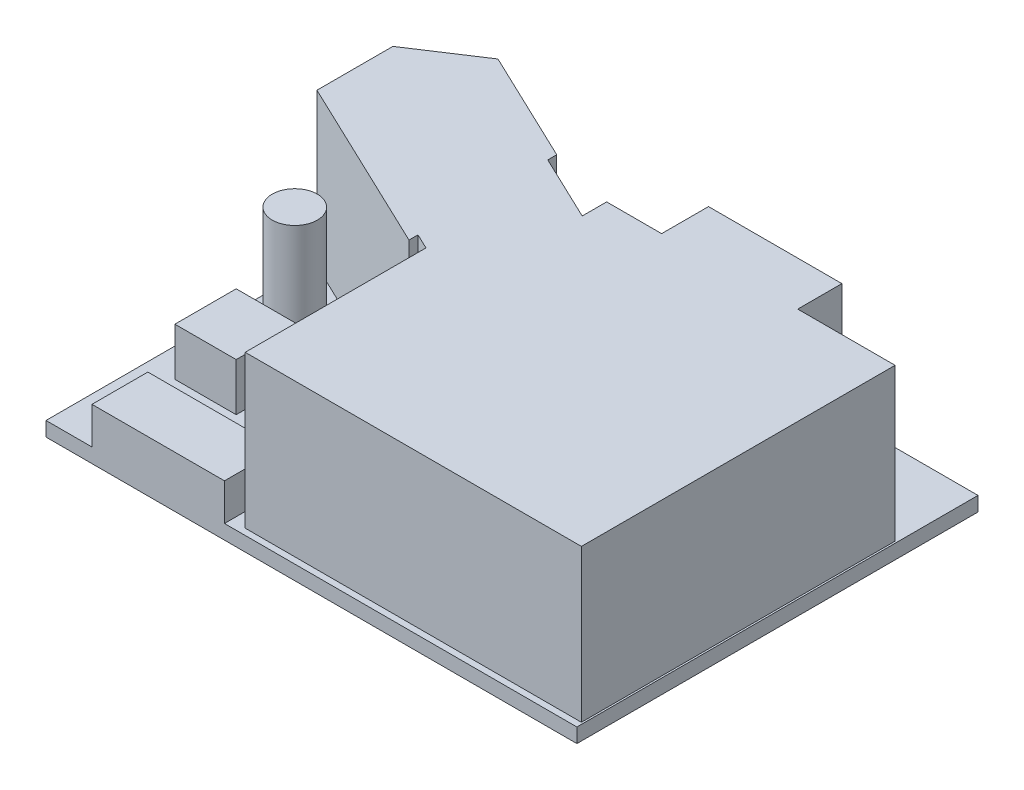
from build123d import *

# Parameters (mm, degrees)
SKETCH1_W           = 58.9
SKETCH1_H           = 44.5
BOSS_EXTRUDE1_DEPTH = 1.6
BOSS_EXTRUDE2_DEPTH = 16.9
SKETCH3_W           = 14.7
SKETCH3_H           = 6.2
BOSS_EXTRUDE3_DEPTH = 4.1
SKETCH3_3_W         = 6.8
SKETCH3_3_H         = 6.8
BOSS_EXTRUDE4_DEPTH = 5.3
SKETCH3_4_R         = 2.5
BOSS_EXTRUDE5_DEPTH = 13.4


with BuildPart() as part:
    # Sketch1 → Boss-Extrude1 (new body)
    with BuildSketch(Plane(origin=(0, 0, 0), x_dir=(1, 0, 0), z_dir=(0, 1, 0))):
        with Locations((12.376180258, -3.819742489)):
            Rectangle(SKETCH1_W, SKETCH1_H)
    extrude(amount=BOSS_EXTRUDE1_DEPTH)

    # Sketch2 → Boss-Extrude2 (add)
    with BuildSketch(Plane(origin=(0, 1.6, 0), x_dir=(1, 0, 0), z_dir=(0, 1, 0))):
        Polygon((-16.873819742, 12.212165342), (-16.873819742, 3.791248246), (2.626180258, -5.499069294), (2.626180258, -4.502146217), (4.326180258, -5.312071336), (4.326180258, -25.369742489), (41.626180258, -25.369742489), (41.626180258, 9.430257511), (30.826180258, 9.430257511), (30.826180258, 14.330257511), (16.026180258, 14.330257511), (16.026180258, 9.130257511), (9.926180258, 9.130257511), (9.926180258, 6.419940037), (2.626180258, 9.897853783), (2.626180258, 10.89477686), (-9.832153076, 16.830257511), align=None)
    extrude(amount=BOSS_EXTRUDE2_DEPTH)

    # Sketch3 → Boss-Extrude3 (add)
    with BuildSketch(Plane(origin=(0, 1.6, 0), x_dir=(1, 0, 0), z_dir=(0, 1, 0))):
        with Locations((-4.623819742, -22.969742489)):
            Rectangle(SKETCH3_W, SKETCH3_H)
    extrude(amount=BOSS_EXTRUDE3_DEPTH)

    # Sketch3_3 → Boss-Extrude4 (add)
    with BuildSketch(Plane(origin=(0, 1.6, 0), x_dir=(1, 0, 0), z_dir=(0, 1, 0))):
        with Locations((-10.473819742, -11.569742489)):
            Rectangle(SKETCH3_3_W, SKETCH3_3_H)
        with Locations((-0.273819742, -11.569742489)):
            Rectangle(SKETCH3_3_W, SKETCH3_3_H)
    extrude(amount=BOSS_EXTRUDE4_DEPTH)

    # Sketch3_4 → Boss-Extrude5 (add)
    with BuildSketch(Plane(origin=(0, 1.6, 0), x_dir=(1, 0, 0), z_dir=(0, 1, 0))):
        with Locations((-10.373819742, -5.169742489)):
            Circle(SKETCH3_4_R)
    extrude(amount=BOSS_EXTRUDE5_DEPTH)


solid = part.part
